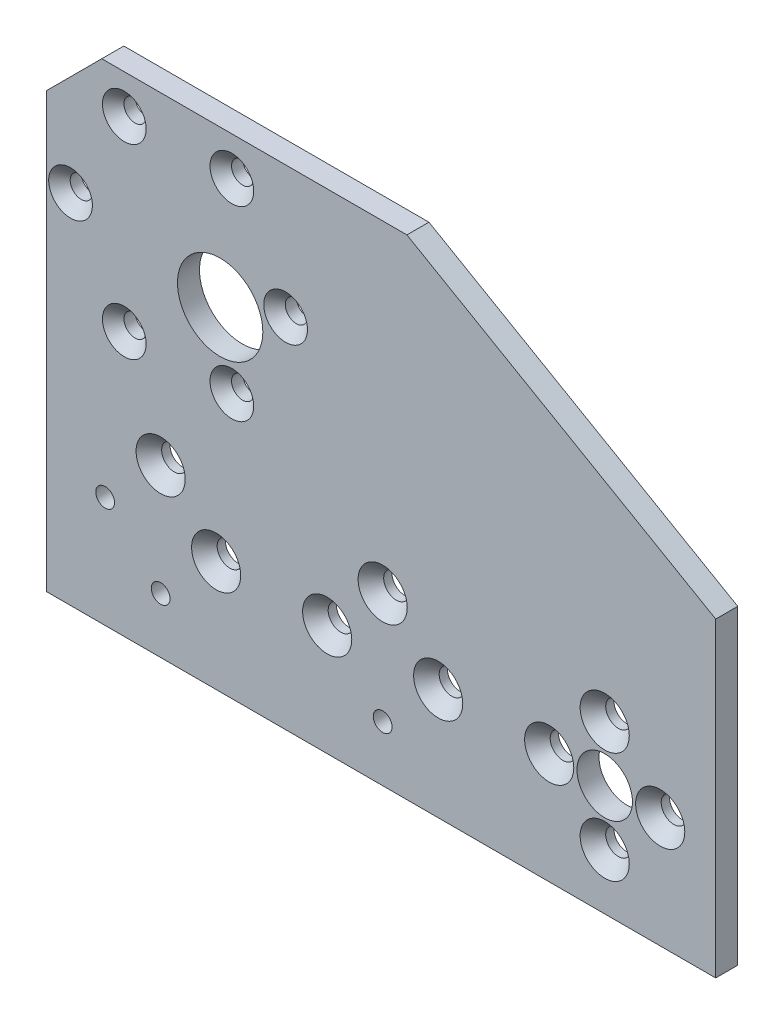
from build123d import *

# Parameters (mm, degrees)
SKETCH1_R                                       = 4
BOSS_EXTRUDE1_DEPTH                             = 3.175
CSK_FOR_M3_FLAT_HEAD_MACHINE_SCREW1_D           = 3.2
CSK_FOR_M3_FLAT_HEAD_MACHINE_SCREW1_CSINK_D     = 6.3
CSK_FOR_M3_FLAT_HEAD_MACHINE_SCREW1_CSINK_ANGLE = 90
F_31_64_0_48438_DIAMETER_HOLE1_D                = 12.303252
CSK_FOR_6_FLAT_HEAD_MACHINE_SCREW1_AT_2_COUNT   = 2
CSK_FOR_6_FLAT_HEAD_MACHINE_SCREW1_AT_2_PITCH   = 11.313708499
CSK_FOR_6_FLAT_HEAD_MACHINE_SCREW1_AT_3_COUNT   = 2
CSK_FOR_6_FLAT_HEAD_MACHINE_SCREW1_AT_3_PITCH   = 16
CSK_FOR_6_FLAT_HEAD_MACHINE_SCREW1_AT_4_COUNT   = 2
CSK_FOR_6_FLAT_HEAD_MACHINE_SCREW1_AT_4_PITCH   = 11.313708499
F_6_32_TAPPED_HOLE1_D                           = 2.7051
CSK_FOR_6_FLAT_HEAD_MACHINE_SCREW2_AT_2_COUNT   = 2
CSK_FOR_6_FLAT_HEAD_MACHINE_SCREW2_AT_2_PITCH   = 11.313708499
CSK_FOR_6_FLAT_HEAD_MACHINE_SCREW2_AT_3_COUNT   = 2
CSK_FOR_6_FLAT_HEAD_MACHINE_SCREW2_AT_3_PITCH   = 32
CSK_FOR_6_FLAT_HEAD_MACHINE_SCREW2_AT_4_COUNT   = 2
CSK_FOR_6_FLAT_HEAD_MACHINE_SCREW2_AT_4_PITCH   = 25.298221281
CSK_FOR_6_FLAT_HEAD_MACHINE_SCREW2_AT_5_COUNT   = 2
CSK_FOR_6_FLAT_HEAD_MACHINE_SCREW2_AT_5_PITCH   = 11.313708499


with BuildPart() as part:
    # Sketch1 → Boss-Extrude1 (new body)
    with BuildSketch(Plane.XY):
        Polygon((16, -16), (-80.487803669, -16), (-80.487803669, 46.5), (-72.487803669, 54.5), (-28.507138544, 54.5), (16, 28.803791581), align=None)
        Circle(SKETCH1_R, mode=Mode.SUBTRACT)
    extrude(amount=-BOSS_EXTRUDE1_DEPTH)

    # CSK for M3 Flat Head Machine Screw1 (through all)
    with Locations(Plane.XY):
        with Locations((-69.237803669, 48.923393759), (-53.737803669, 48.923393759), (-45.987803669, 35.5), (-53.737803669, 22.076606241), (-69.237803669, 22.076606241), (-76.987803669, 35.5)):
            CounterSinkHole(CSK_FOR_M3_FLAT_HEAD_MACHINE_SCREW1_D / 2, CSK_FOR_M3_FLAT_HEAD_MACHINE_SCREW1_CSINK_D / 2, counter_sink_angle=CSK_FOR_M3_FLAT_HEAD_MACHINE_SCREW1_CSINK_ANGLE)

    # 31_64 _0.48438_ Diameter Hole1 (through all)
    with Locations(Plane.XY):
        with Locations((-55.425625842, 32)):
            Hole(F_31_64_0_48438_DIAMETER_HOLE1_D / 2)

    # Sketch8 → CSK for _6 Flat Head Machine Screw1 (revolve, cut)
    with BuildSketch(Plane(origin=(0, 8, 0), x_dir=(0, -1, 0), z_dir=(1, 0, 0))):
        Polygon((0, 0), (0, 3.175), (1.8288, 3.175), (1.8288, 1.972306634), (3.5433, 0), align=None)
    csk_for_6_flat_head_machine_screw1 = revolve(axis=Axis((0, 8, 6.35), (0, 0, -1)), mode=Mode.SUBTRACT)

    # CSK for _6 Flat Head Machine Screw1 at 2: CSK for _6 Flat Head Machine Screw1 ×2
    with Locations(*[Vector(-0.7071067811865479, -0.7071067811865472, 0) * (i * CSK_FOR_6_FLAT_HEAD_MACHINE_SCREW1_AT_2_PITCH) for i in range(1, CSK_FOR_6_FLAT_HEAD_MACHINE_SCREW1_AT_2_COUNT)]):
        add(csk_for_6_flat_head_machine_screw1, mode=Mode.SUBTRACT)

    # CSK for _6 Flat Head Machine Screw1 at 3: CSK for _6 Flat Head Machine Screw1 ×2
    with Locations(*[(0, -i * CSK_FOR_6_FLAT_HEAD_MACHINE_SCREW1_AT_3_PITCH, 0) for i in range(1, CSK_FOR_6_FLAT_HEAD_MACHINE_SCREW1_AT_3_COUNT)]):
        add(csk_for_6_flat_head_machine_screw1, mode=Mode.SUBTRACT)

    # CSK for _6 Flat Head Machine Screw1 at 4: CSK for _6 Flat Head Machine Screw1 ×2
    with Locations(*[Vector(0.7071067811865475, -0.7071067811865477, 0) * (i * CSK_FOR_6_FLAT_HEAD_MACHINE_SCREW1_AT_4_PITCH) for i in range(1, CSK_FOR_6_FLAT_HEAD_MACHINE_SCREW1_AT_4_COUNT)]):
        add(csk_for_6_flat_head_machine_screw1, mode=Mode.SUBTRACT)

    # 6-32 Tapped Hole1 (through all)
    with Locations(Plane.XY):
        with Locations((-72, 0), (-32, -8), (-64, -8)):
            Hole(F_6_32_TAPPED_HOLE1_D / 2)

    # Sketch13 → CSK for _6 Flat Head Machine Screw2 (revolve, cut)
    with BuildSketch(Plane(origin=(-32, 8, 0), x_dir=(0, -1, 0), z_dir=(1, 0, 0))):
        Polygon((0, 0), (0, 3.175), (1.8288, 3.175), (1.8288, 1.972306634), (3.5433, 0), align=None)
    csk_for_6_flat_head_machine_screw2 = revolve(axis=Axis((-32, 8, 6.35), (0, 0, -1)), mode=Mode.SUBTRACT)

    # CSK for _6 Flat Head Machine Screw2 at 2: CSK for _6 Flat Head Machine Screw2 ×2
    with Locations(*[Vector(0.7071067811865476, -0.7071067811865476, 0) * (i * CSK_FOR_6_FLAT_HEAD_MACHINE_SCREW2_AT_2_PITCH) for i in range(1, CSK_FOR_6_FLAT_HEAD_MACHINE_SCREW2_AT_2_COUNT)]):
        add(csk_for_6_flat_head_machine_screw2, mode=Mode.SUBTRACT)

    # CSK for _6 Flat Head Machine Screw2 at 3: CSK for _6 Flat Head Machine Screw2 ×2
    with Locations(*[(-i * CSK_FOR_6_FLAT_HEAD_MACHINE_SCREW2_AT_3_PITCH, 0, 0) for i in range(1, CSK_FOR_6_FLAT_HEAD_MACHINE_SCREW2_AT_3_COUNT)]):
        add(csk_for_6_flat_head_machine_screw2, mode=Mode.SUBTRACT)

    # CSK for _6 Flat Head Machine Screw2 at 4: CSK for _6 Flat Head Machine Screw2 ×2
    with Locations(*[Vector(-0.948683298050514, -0.31622776601683766, 0) * (i * CSK_FOR_6_FLAT_HEAD_MACHINE_SCREW2_AT_4_PITCH) for i in range(1, CSK_FOR_6_FLAT_HEAD_MACHINE_SCREW2_AT_4_COUNT)]):
        add(csk_for_6_flat_head_machine_screw2, mode=Mode.SUBTRACT)

    # CSK for _6 Flat Head Machine Screw2 at 5: CSK for _6 Flat Head Machine Screw2 ×2
    with Locations(*[Vector(-0.7071067811865476, -0.7071067811865476, 0) * (i * CSK_FOR_6_FLAT_HEAD_MACHINE_SCREW2_AT_5_PITCH) for i in range(1, CSK_FOR_6_FLAT_HEAD_MACHINE_SCREW2_AT_5_COUNT)]):
        add(csk_for_6_flat_head_machine_screw2, mode=Mode.SUBTRACT)


solid = part.part
